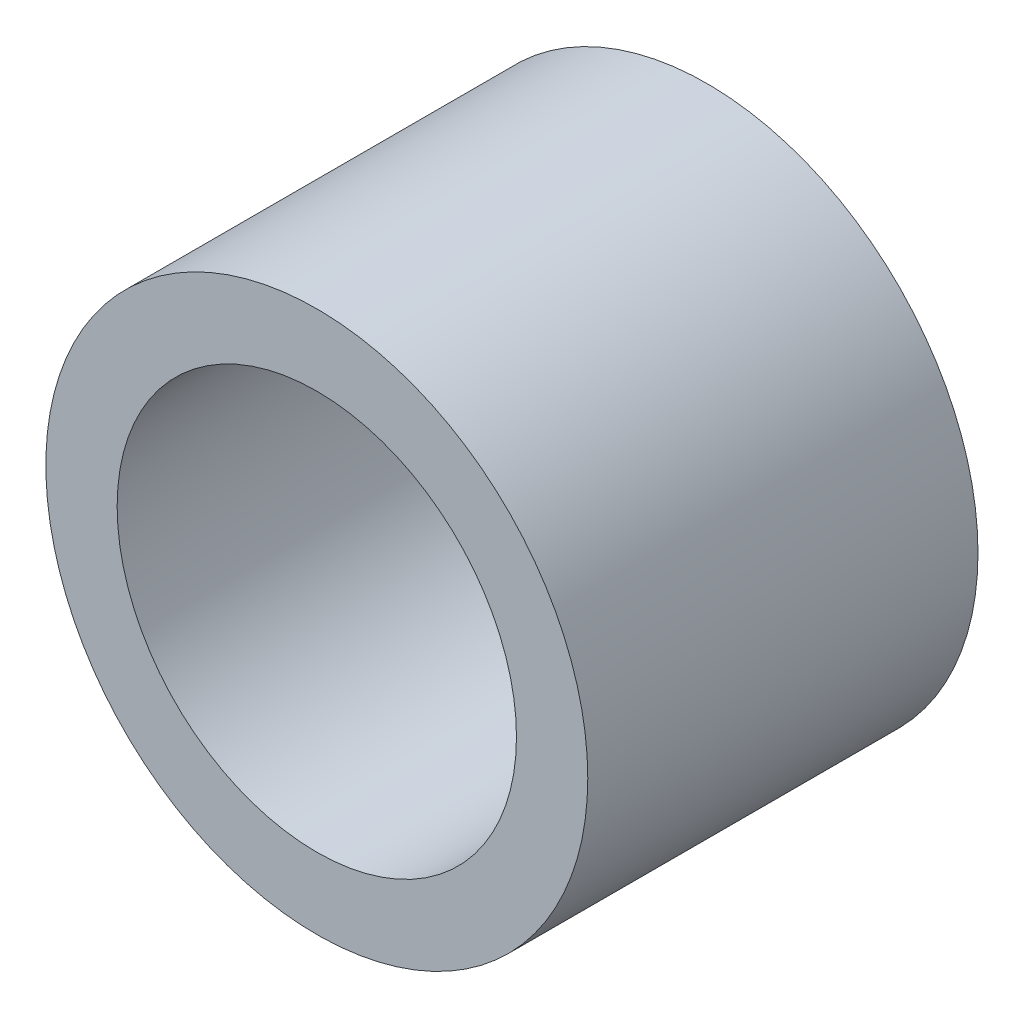
from build123d import *

# Parameters (mm, degrees)
SKETCH1_R           = 4.826
SKETCH1_R_2         = 3.556
BOSS_EXTRUDE1_DEPTH = 6.94944


with BuildPart() as part:
    # Sketch1 → Boss-Extrude1 (new body)
    with BuildSketch(Plane.XY):
        Circle(SKETCH1_R)
        Circle(SKETCH1_R_2, mode=Mode.SUBTRACT)
    extrude(amount=BOSS_EXTRUDE1_DEPTH)


solid = part.part
